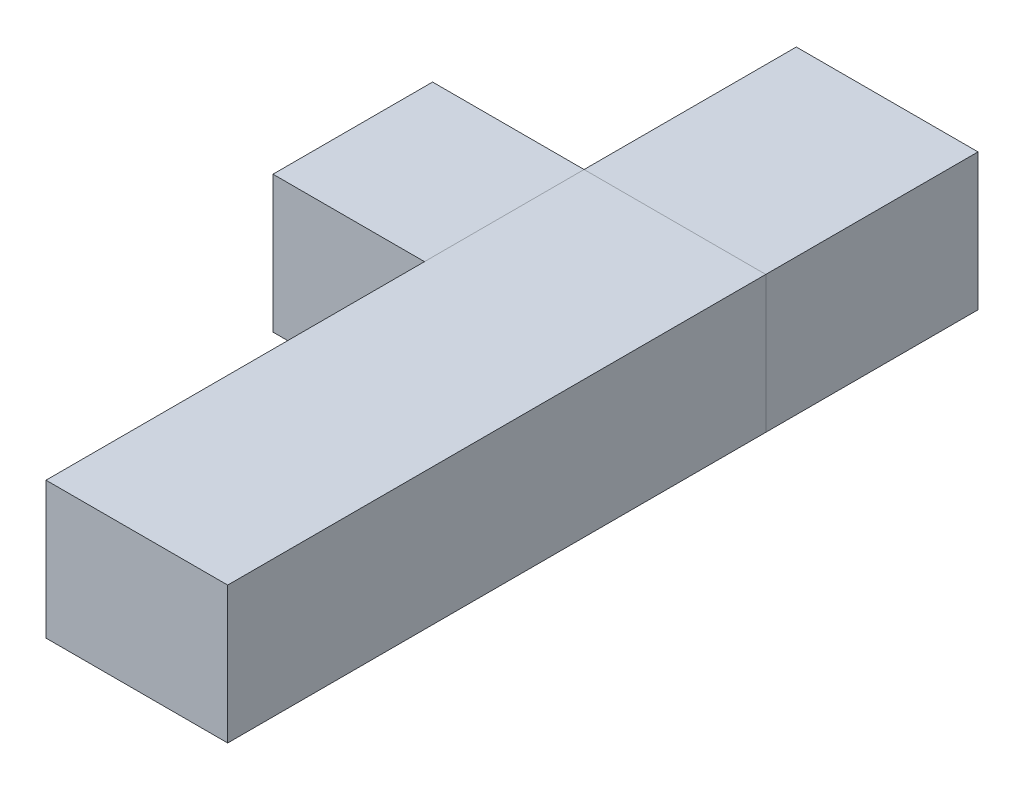
from build123d import *

# Parameters (mm, degrees)
SKETCH1_W                = 25.4
SKETCH1_H                = 19.05
BOSS_EXTRUDE1_DEPTH      = 9.525
SKETCH2_OUTSIDE_W        = 34.806
SKETCH2_OUTSIDE_H        = 28.456
CUT_EXTRUDE2_DEPTH       = 10.525
CUT_EXTRUDE2_DEPTH_BACK  = 10.525
SKETCH3_R                = 6.604
CUT_EXTRUDE3_DEPTH       = 6.477
SKETCH5_R                = 3.175
CUT_EXTRUDE5_DEPTH       = 10.525
CUT_EXTRUDE5_DEPTH_BACK  = 10.525
SKETCH4_W                = 3.175
SKETCH4_H                = 4.8895
CUT_EXTRUDE4_DEPTH       = 13.7
CUT_EXTRUDE4_DEPTH_BACK  = 13.7
CUT_EXTRUDE6_DEPTH       = 1.5875
SKETCH7_W                = 8.89
SKETCH7_H                = 4.8895
CUT_EXTRUDE7_DEPTH       = 10.525
CUT_EXTRUDE7_DEPTH_BACK  = 10.525
SKETCH8_W                = 8.89
SKETCH8_H                = 2.794
SKETCH8_H_2              = 5.842
CUT_EXTRUDE8_DEPTH       = 10.525
CUT_EXTRUDE8_DEPTH_BACK  = 10.525
CUT_EXTRUDE9_DEPTH       = 8.6835
CUT_EXTRUDE9_DEPTH_BACK  = 12.3665
SKETCH11_R               = 0.5953125
CUT_EXTRUDE11_DEPTH      = 12.3665
FILLET1_R                = 3.175
SKETCH15_R               = 4.064
CUT_EXTRUDE12_DEPTH      = 6.842
SKETCH22_R               = 4.064
CUT_EXTRUDE15_DEPTH      = 8.6835
SKETCH16_W               = 3.175
SKETCH16_H               = 6.972783942
BOSS_EXTRUDE4_DEPTH      = 3.12674
SKETCH18_W               = 3.175
SKETCH18_H               = 6.972783942
BOSS_EXTRUDE5_DEPTH      = 3.12674
SKETCH19_R               = 0.7493
CUT_EXTRUDE13_DEPTH      = 17.497783942
SKETCH20_R               = 0.7493
CUT_EXTRUDE14_DEPTH      = 17.497783942
SKETCH26_W               = 46.403914144
SKETCH26_H               = 19.05
BOSS_EXTRUDE8_DEPTH      = 9.525
BOSS_EXTRUDE8_DEPTH_BACK = 12.7
SKETCH23_W               = 25.30348
SKETCH23_H               = 74.938767094
BOSS_EXTRUDE6_DEPTH      = 9.652
BOSS_EXTRUDE6_DEPTH_BACK = 9.398
SKETCH24_W               = 25.30348
SKETCH24_H               = 51.781364698
BOSS_EXTRUDE7_DEPTH      = 9.652
BOSS_EXTRUDE7_DEPTH_BACK = 9.398


with BuildPart() as part:
    # Sketch1 → Boss-Extrude1 (new body, symmetric)
    with BuildSketch(Plane(origin=(0, 0, 0), x_dir=(0, 0, -1), z_dir=(1, 0, 0))):
        with Locations((0, 0.127)):
            Rectangle(SKETCH1_W, SKETCH1_H)
    extrude(amount=BOSS_EXTRUDE1_DEPTH, both=True)

    # Sketch2 outside → Cut-Extrude2 (cut, two sides)
    with BuildSketch(Plane(origin=(0, 0, 0), x_dir=(0, 0, -1), z_dir=(1, 0, 0))) as cut_extrude2_sk:
        with Locations((0, 0.127)):
            Rectangle(SKETCH2_OUTSIDE_W, SKETCH2_OUTSIDE_H)
        with BuildLine():
            Line((1.859871939, -4.490128061), (-3.048, -9.398))
            Line((-3.048, -9.398), (-12.7, -9.398))
            Line((-12.7, -9.398), (-12.7, 9.652))
            Line((-12.7, 9.652), (2.352010696, 9.652))
            Line((2.352010696, 9.652), (3.919960204, 5.866635031))
            ThreePointArc((3.919960204, 5.866635031), (12.577986531, -1.238823545), (1.859871939, -4.490128061))
        make_face(mode=Mode.SUBTRACT)
    extrude(amount=CUT_EXTRUDE2_DEPTH, mode=Mode.SUBTRACT)
    extrude(cut_extrude2_sk.sketch, amount=-CUT_EXTRUDE2_DEPTH_BACK, mode=Mode.SUBTRACT)

    # Sketch3 → Cut-Extrude3 (cut, symmetric)
    with BuildSketch(Plane(origin=(0, 0, 0), x_dir=(0, 0, -1), z_dir=(1, 0, 0))):
        with Locations((6.35, 0)):
            Circle(SKETCH3_R)
    extrude(amount=CUT_EXTRUDE3_DEPTH, both=True, mode=Mode.SUBTRACT)

    # Sketch5 → Cut-Extrude5 (cut, two sides)
    with BuildSketch(Plane(origin=(0, 0, 0), x_dir=(0, 0, -1), z_dir=(1, 0, 0))) as cut_extrude5_sk:
        with Locations((6.35, 0)):
            Circle(SKETCH5_R)
    extrude(amount=CUT_EXTRUDE5_DEPTH, mode=Mode.SUBTRACT)
    extrude(cut_extrude5_sk.sketch, amount=-CUT_EXTRUDE5_DEPTH_BACK, mode=Mode.SUBTRACT)

    # Sketch4 → Cut-Extrude4 (cut, two sides)
    with BuildSketch(Plane.XY) as cut_extrude4_sk:
        with Locations((0, 7.20725)):
            Rectangle(SKETCH4_W, SKETCH4_H)
    extrude(amount=CUT_EXTRUDE4_DEPTH, mode=Mode.SUBTRACT)
    extrude(cut_extrude4_sk.sketch, amount=-CUT_EXTRUDE4_DEPTH_BACK, mode=Mode.SUBTRACT)

    # Sketch6 → Cut-Extrude6 (cut, symmetric)
    with BuildSketch(Plane(origin=(0, 0, 0), x_dir=(0, 0, -1), z_dir=(1, 0, 0))):
        Polygon((0, -6.35), (-3.048, -9.398), (-12.7, -9.398), (-12.7, -6.35), align=None)
    extrude(amount=CUT_EXTRUDE6_DEPTH, both=True, mode=Mode.SUBTRACT)

    # Sketch7 → Cut-Extrude7 (cut, two sides)
    with BuildSketch(Plane(origin=(0, 0, 0), x_dir=(0, 0, -1), z_dir=(1, 0, 0))) as cut_extrude7_sk:
        with Locations((-8.255, 7.20725)):
            Rectangle(SKETCH7_W, SKETCH7_H)
    extrude(amount=CUT_EXTRUDE7_DEPTH, mode=Mode.SUBTRACT)
    extrude(cut_extrude7_sk.sketch, amount=-CUT_EXTRUDE7_DEPTH_BACK, mode=Mode.SUBTRACT)

    # Sketch8 → Cut-Extrude8 (cut, two sides)
    with BuildSketch(Plane(origin=(0, 0, 0), x_dir=(0, 0, -1), z_dir=(1, 0, 0))) as cut_extrude8_sk:
        with Locations((-8.255, 3.3655)):
            Rectangle(SKETCH8_W, SKETCH8_H)
        with Locations((-8.255, -6.477)):
            Rectangle(SKETCH8_W, SKETCH8_H_2)
    extrude(amount=CUT_EXTRUDE8_DEPTH, mode=Mode.SUBTRACT)
    extrude(cut_extrude8_sk.sketch, amount=-CUT_EXTRUDE8_DEPTH_BACK, mode=Mode.SUBTRACT)

    # Sketch9 → Cut-Extrude9 (cut, two sides)
    with BuildSketch(Plane(origin=(0, 1.9685, 0), x_dir=(1, 0, 0), z_dir=(0, 1, 0))) as cut_extrude9_sk:
        with BuildLine():
            Line((-3.066814498, -5.528249532), (-9.525, -3.797783942))
            Line((-9.525, -3.797783942), (-9.525, -12.7))
            Line((-9.525, -12.7), (9.525, -12.7))
            Line((9.525, -12.7), (9.525, -3.797783942))
            Line((9.525, -3.797783942), (3.066814498, -5.528249532))
            ThreePointArc((3.066814498, -5.528249532), (0, -9.525), (-3.066814498, -5.528249532))
        make_face()
    extrude(amount=CUT_EXTRUDE9_DEPTH, mode=Mode.SUBTRACT)
    extrude(cut_extrude9_sk.sketch, amount=-CUT_EXTRUDE9_DEPTH_BACK, mode=Mode.SUBTRACT)

    # Sketch11 → Cut-Extrude11 (cut, through all)
    with BuildSketch(Plane(origin=(0, 1.9685, 0), x_dir=(1, 0, 0), z_dir=(0, 1, 0))):
        with Locations((0, -6.35)):
            Circle(SKETCH11_R)
    extrude(amount=-CUT_EXTRUDE11_DEPTH, mode=Mode.SUBTRACT)

    # Fillet1
    fillet1_edges = [part.edges().sort_by_distance(p)[0] for p in [
        (9.525, 9.652, 0.722886623),
        (-9.525, 9.652, 0.722886623),
    ]]
    fillet(fillet1_edges, radius=FILLET1_R)

    # Sketch15 → Cut-Extrude12 (cut, through all)
    with BuildSketch(Plane.XZ.offset(3.556)):
        with Locations((0, 6.35)):
            Circle(SKETCH15_R)
    extrude(amount=CUT_EXTRUDE12_DEPTH, mode=Mode.SUBTRACT)

    # Sketch22 → Cut-Extrude15 (cut, through all)
    with BuildSketch(Plane(origin=(0, 1.9685, 0), x_dir=(1, 0, 0), z_dir=(0, 1, 0))):
        with Locations((0, -6.35)):
            Circle(SKETCH22_R)
    extrude(amount=CUT_EXTRUDE15_DEPTH, mode=Mode.SUBTRACT)

    # Sketch16 → Boss-Extrude4 (add)
    with BuildSketch(Plane(origin=(9.525, 0, 0), x_dir=(0, 0, -1), z_dir=(1, 0, 0))):
        with Locations((-2.210283942, -3.486391971)):
            Rectangle(SKETCH16_W, SKETCH16_H)
    extrude(amount=BOSS_EXTRUDE4_DEPTH)

    # Sketch18 → Boss-Extrude5 (add)
    with BuildSketch(Plane.ZY.offset(9.525)):
        with Locations((2.210283942, -3.486391971)):
            Rectangle(SKETCH18_W, SKETCH18_H)
    extrude(amount=BOSS_EXTRUDE5_DEPTH)

    # Sketch19 → Cut-Extrude13 (cut, through all)
    with BuildSketch(Plane.XY.offset(3.797783942)):
        with Locations((11.08837, -4.7625)):
            Circle(SKETCH19_R)
    extrude(amount=-CUT_EXTRUDE13_DEPTH, mode=Mode.SUBTRACT)

    # Sketch20 → Cut-Extrude14 (cut, through all)
    with BuildSketch(Plane.XY.offset(3.797783942)):
        with Locations((-11.08837, -4.7625)):
            Circle(SKETCH20_R)
    extrude(amount=-CUT_EXTRUDE14_DEPTH, mode=Mode.SUBTRACT)


with BuildPart() as body_2:
    # Sketch26 → Boss-Extrude8 (new body, two sides)
    with BuildSketch(Plane.XY) as boss_extrude8_sk:
        with Locations((-10.550217072, 0.127)):
            Rectangle(SKETCH26_W, SKETCH26_H)
    extrude(amount=BOSS_EXTRUDE8_DEPTH)
    extrude(boss_extrude8_sk.sketch, amount=-BOSS_EXTRUDE8_DEPTH_BACK)


with BuildPart() as body_3:
    # Sketch23 → Boss-Extrude6 (new body, two sides)
    with BuildSketch(Plane(origin=(0, 0, 0), x_dir=(1, 0, 0), z_dir=(0, 1, 0))) as boss_extrude6_sk:
        with Locations((0, -24.769383547)):
            Rectangle(SKETCH23_W, SKETCH23_H)
    extrude(amount=BOSS_EXTRUDE6_DEPTH)
    extrude(boss_extrude6_sk.sketch, amount=-BOSS_EXTRUDE6_DEPTH_BACK)


with BuildPart() as body_4:
    # Sketch24 → Boss-Extrude7 (new body, two sides)
    with BuildSketch(Plane(origin=(0, 0, 0), x_dir=(1, 0, 0), z_dir=(0, 1, 0))) as boss_extrude7_sk:
        with Locations((0, 16.365682349)):
            Rectangle(SKETCH24_W, SKETCH24_H)
    extrude(amount=BOSS_EXTRUDE7_DEPTH)
    extrude(boss_extrude7_sk.sketch, amount=-BOSS_EXTRUDE7_DEPTH_BACK)


solid = Compound([part.part, body_2.part, body_3.part, body_4.part])
